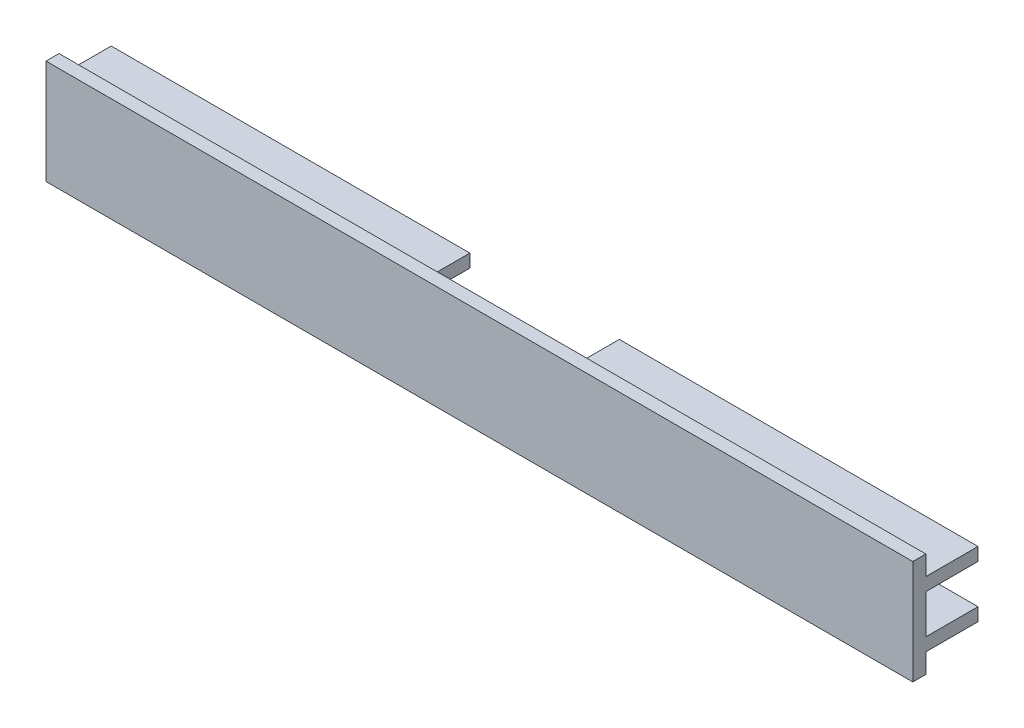
from build123d import *

# Parameters (mm, degrees)
EXTRUDE1_DEPTH = 66.46
SKETCH2_W      = 1
SKETCH2_H      = 6
EXTRUDE2_DEPTH = 32
SKETCH3_W      = 1
SKETCH3_H      = 6
EXTRUDE3_DEPTH = 32
EXTRUDE4_DEPTH = 1
SKETCH5_W      = 22.92
SKETCH5_H      = 10
EXTRUDE5_DEPTH = 7


with BuildPart() as part:
    # Sketch1 → Extrude1 (new body, symmetric)
    with BuildSketch(Plane(origin=(0, 0, 0), x_dir=(0, 0, -1), z_dir=(1, 0, 0))):
        Polygon((-3, 8), (-3, 5), (5, 5), (5, 3), (-2, 3), (-2, -3), (5, -3), (5, -5), (-3, -5), (-3, -8), (-5, -8), (-5, 8), align=None)
    extrude(amount=EXTRUDE1_DEPTH, both=True)

    # Sketch2 → Extrude2 (cut)
    with BuildSketch(Plane.ZY.offset(66.46)):
        with Locations((2.5, 0)):
            Rectangle(SKETCH2_W, SKETCH2_H)
    extrude(amount=-EXTRUDE2_DEPTH, mode=Mode.SUBTRACT)

    # Sketch3 → Extrude3 (cut)
    with BuildSketch(Plane(origin=(66.46, 0, 0), x_dir=(0, 0, -1), z_dir=(1, 0, 0))):
        with Locations((-2.5, 0)):
            Rectangle(SKETCH3_W, SKETCH3_H)
    extrude(amount=-EXTRUDE3_DEPTH, mode=Mode.SUBTRACT)

    # Sketch4 → Extrude4 (cut)
    with BuildSketch(Plane(origin=(0, 0, 2), x_dir=(-1, 0, 0), z_dir=(0, 0, -1))):
        with BuildLine():
            Line((-34.46, 3), (-34.46, -3))
            ThreePointArc((-34.46, -3), (-31.46, 0), (-34.46, 3))
        make_face()
        with BuildLine():
            Line((34.46, 3), (34.46, -3))
            ThreePointArc((34.46, -3), (31.46, 0), (34.46, 3))
        make_face()
    extrude(amount=-EXTRUDE4_DEPTH, mode=Mode.SUBTRACT)

    # Sketch5 → Extrude5 (cut)
    with BuildSketch(Plane(origin=(0, 0, -5), x_dir=(-1, 0, 0), z_dir=(0, 0, -1))):
        Rectangle(SKETCH5_W, SKETCH5_H)
    extrude(amount=-EXTRUDE5_DEPTH, mode=Mode.SUBTRACT)


solid = part.part
